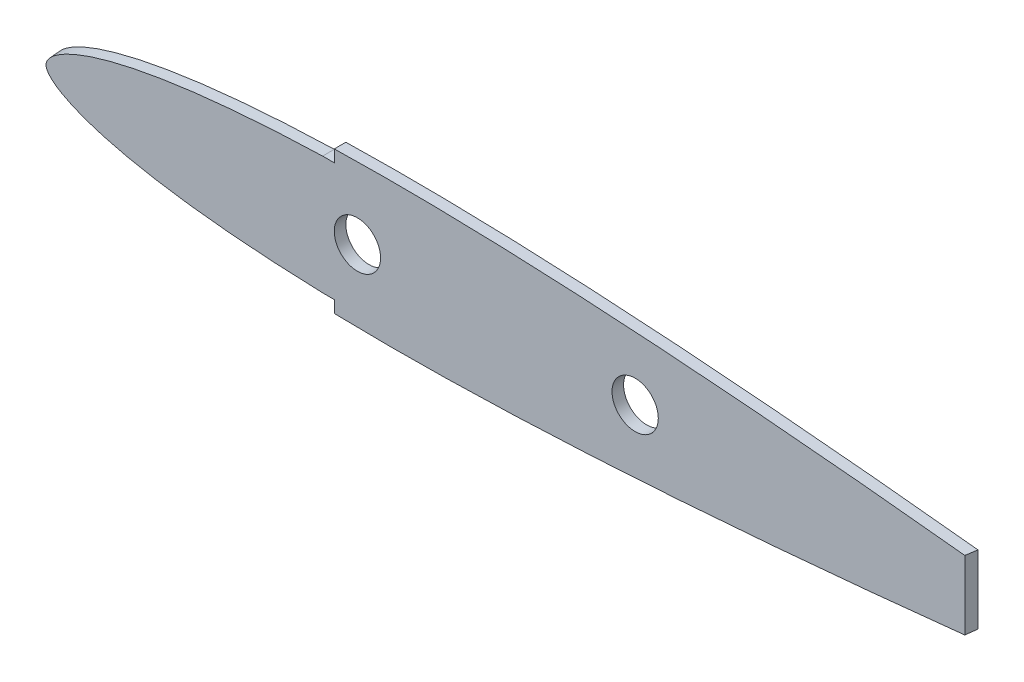
from build123d import *

# Parameters (mm, degrees)
BOSS_EXTRUDE1_DEPTH     = 3.175
SKETCH2_R               = 6.35
CUT_EXTRUDE1_DEPTH      = 4.1750001
CUT_EXTRUDE2_DEPTH      = 20.741500936
CUT_EXTRUDE2_DEPTH_BACK = 20.741500936


with BuildPart() as part:
    # Sketch1 → Boss-Extrude1 (new body)
    with BuildSketch(Plane.XY):
        with BuildLine():
            add(Edge.make_bspline(
                [(328.93, 0.4144518), (328.807900642, 0.516772717), (328.019000541, 0.420161926), (326.614170865, 0.815622818), (324.037900124, 1.060053788), (320.567272172, 1.584632638), (316.096583479, 2.170027594), (310.705215164, 2.891499965), (304.407193949, 3.70705594), (297.248126622, 4.61507178), (289.269853683, 5.599640546), (280.522284399, 6.647437516), (271.05918713, 7.745466949), (260.938835986, 8.878779448), (250.223661724, 10.033538187), (238.979802735, 11.195400912), (227.276553794, 12.349370833), (215.186101231, 13.479249677), (202.78290329, 14.570204468), (190.143565404, 15.603996393), (177.345750776, 16.563769435), (164.468478458, 17.43170464), (151.591090461, 18.189654233), (138.792862913, 18.818469572), (126.15283726, 19.301382712), (113.748578816, 19.622639213), (101.656743367, 19.766547691), (89.951630239, 19.721687508), (78.705404506, 19.479393557), (67.987291822, 19.033523951), (57.863264224, 18.382912366), (48.395544354, 17.529516447), (39.642067919, 16.480001255), (31.656190162, 15.24329661), (24.486303571, 13.832318834), (18.174431838, 12.263022231), (12.756441756, 10.550709399), (8.259860269, 8.711328155), (4.699027102, 6.757322776), (2.079421527, 4.684836659), (0.401585469, 2.443731656), (-0.187153107, 0), (0.401585469, -2.443731656), (2.079421527, -4.684836659), (4.699027102, -6.757322776), (8.259860269, -8.711328155), (12.756441756, -10.550709399), (18.174431838, -12.263022231), (24.486303571, -13.832318834), (31.656190162, -15.24329661), (39.642067919, -16.480001255), (48.395544354, -17.529516447), (57.863264224, -18.382912366), (67.987291822, -19.033523951), (78.705404506, -19.479393557), (89.951630239, -19.721687508), (101.656743367, -19.766547691), (113.748578816, -19.622639213), (126.15283726, -19.301382712), (138.792862913, -18.818469572), (151.591090461, -18.189654233), (164.468478458, -17.43170464), (177.345750776, -16.563769435), (190.143565404, -15.603996393), (202.78290329, -14.570204468), (215.186101231, -13.479249677), (227.276553794, -12.349370833), (238.979802735, -11.195400912), (250.223661724, -10.033538187), (260.938835986, -8.878779448), (271.05918713, -7.745466949), (280.522284399, -6.647437516), (289.269853683, -5.599640546), (297.248126622, -4.61507178), (304.407193949, -3.70705594), (310.705215164, -2.891499965), (316.096583479, -2.170027594), (320.567272172, -1.584632638), (324.037900124, -1.060053788), (326.614170865, -0.815622818), (328.019000541, -0.420161926), (329.127736254, -0.555940631), (329.127736254, 0.24874614), (328.93, 0.4144518)],
                knots=[0, 0, 0, 0, 0.000762215, 0.003044706, 0.006832246, 0.012101176, 0.018817536, 0.026939455, 0.036414848, 0.047184629, 0.059180413, 0.072327874, 0.086544061, 0.10174058, 0.117823336, 0.134691452, 0.152240154, 0.17036129, 0.188941008, 0.207865435, 0.227016078, 0.246275696, 0.265524943, 0.284644966, 0.303520118, 0.322034575, 0.340078353, 0.357542593, 0.374325482, 0.390329891, 0.40546389, 0.419643801, 0.432793371, 0.444843817, 0.455737921, 0.465428653, 0.47388632, 0.481101634, 0.487101684, 0.491975368, 0.495930678, 0.499382808, 0.502834938, 0.506790248, 0.511663932, 0.517663982, 0.524879296, 0.533336963, 0.543027695, 0.553921799, 0.565972245, 0.579121815, 0.593301726, 0.608435725, 0.624440134, 0.641223023, 0.658687263, 0.676731041, 0.695245498, 0.71412065, 0.733240673, 0.75248992, 0.771749538, 0.790900181, 0.809824608, 0.828404326, 0.846525462, 0.864074164, 0.88094228, 0.897025036, 0.912221555, 0.926437743, 0.939585203, 0.951580988, 0.962350768, 0.971826161, 0.979948081, 0.98666444, 0.991933371, 0.99572091, 0.998003402, 0.998765616, 1, 1, 1, 1], degree=3))
        make_face()
    extrude(amount=BOSS_EXTRUDE1_DEPTH)

    # Sketch2 → Cut-Extrude1 (cut, through all)
    with BuildSketch(Plane.XY.offset(3.175)):
        with Locations((88.9, 0)):
            Circle(SKETCH2_R)
        with Locations((165.1, 0)):
            Circle(SKETCH2_R)
    extrude(amount=-CUT_EXTRUDE1_DEPTH, mode=Mode.SUBTRACT)

    # Sketch3 → Cut-Extrude2 (cut, two sides)
    with BuildSketch(Plane(origin=(0, 0, 0), x_dir=(1, 0, 0), z_dir=(0, 1, 0))) as cut_extrude2_sk:
        Polygon((255.992242673, 0), (255.545593987, -3.175), (329.07830219, -3.175), (329.07830219, 0), align=None)
    extrude(amount=CUT_EXTRUDE2_DEPTH, mode=Mode.SUBTRACT)
    extrude(cut_extrude2_sk.sketch, amount=-CUT_EXTRUDE2_DEPTH_BACK, mode=Mode.SUBTRACT)

    # Sketch4 → Cut-Loft1 section 0
    with BuildSketch(Plane.XY.offset(3.175)):
        with BuildLine():
            Line((82.55, -19.515708197), (82.55, -16.251023077))
            Line((82.55, -16.251023077), (79.375, -16.251023077))
            add(Edge.make_bspline(
                [(79.375, 16.251023077), (72.770318552, 16.048049675), (66.176202719, 15.728304371), (56.30738853, 15.001567412), (53.021532705, 14.717888762), (46.459157571, 14.04734399), (43.182596705, 13.660937457), (38.276882967, 12.980450934), (36.643177419, 12.736779299), (33.379494145, 12.209172355), (31.748117674, 11.925180268), (28.498717967, 11.31067673), (26.880571377, 10.97988905), (23.660292552, 10.260780921), (22.058116365, 9.87261787), (18.875212279, 9.019251619), (17.293996052, 8.555526619), (14.162834442, 7.517257926), (12.611952901, 6.946125273), (10.325000489, 5.950076454), (9.567811499, 5.594025093), (8.461932827, 5.017489815), (8.097932617, 4.81777412), (7.381669561, 4.39922172), (7.029407018, 4.180395983), (6.339282138, 3.719594292), (6.001169966, 3.47795005), (5.346762375, 2.959692647), (5.02857237, 2.681117584), (4.439349211, 2.084395549), (4.164695388, 1.768387828), (3.820228536, 1.236176286), (3.718740433, 1.050561172), (3.59999989, 0.759299745), (3.565442077, 0.659141625), (3.509216677, 0.455376556), (3.487522742, 0.351764773), (3.459675736, 0.143592536), (3.453573255, 0.038940089), (3.461444597, -0.171798071), (3.474973766, -0.278422694), (3.536160139, -0.588423887), (3.603651886, -0.78636311), (3.780189655, -1.168677669), (3.889538593, -1.351988295), (4.129382817, -1.699026003), (4.261329389, -1.864987348), (4.67775825, -2.342961513), (4.979594961, -2.63427888), (5.614334641, -3.181856059), (5.947755344, -3.437548737), (6.980186178, -4.167859174), (7.695486627, -4.59881642), (9.156342741, -5.391257516), (9.902423269, -5.75319572), (11.414841066, -6.432708068), (12.181579116, -6.749404985), (13.73156777, -7.346635451), (14.514836956, -7.627179806), (16.093189665, -8.161972373), (16.88860874, -8.415184993), (18.482918694, -8.896317804), (19.282763312, -9.124717403), (21.688920309, -9.779957105), (23.302005405, -10.176164111), (26.541461257, -10.908476052), (28.167798474, -11.244732377), (33.062961618, -12.180447863), (36.350545365, -12.709560737), (42.938422768, -13.630876096), (46.23811967, -14.02274496), (52.84624923, -14.702163706), (56.154743063, -14.989298509), (66.090451195, -15.724271447), (72.727906329, -16.046777883), (79.375, -16.251023077)],
                knots=[0, 0, 0, 0, 0.125, 0.125, 0.1875, 0.1875, 0.25, 0.25, 0.28125, 0.28125, 0.3125, 0.3125, 0.34375, 0.34375, 0.375, 0.375, 0.40625, 0.40625, 0.4375, 0.4375, 0.453125, 0.453125, 0.4609375, 0.4609375, 0.46875, 0.46875, 0.4765625, 0.4765625, 0.484375, 0.484375, 0.4921875, 0.4921875, 0.49609375, 0.49609375, 0.498046875, 0.498046875, 0.5, 0.5, 0.501953125, 0.501953125, 0.50390625, 0.50390625, 0.5078125, 0.5078125, 0.51171875, 0.51171875, 0.515625, 0.515625, 0.5234375, 0.5234375, 0.53125, 0.53125, 0.546875, 0.546875, 0.5625, 0.5625, 0.578125, 0.578125, 0.59375, 0.59375, 0.609375, 0.609375, 0.625, 0.625, 0.65625, 0.65625, 0.6875, 0.6875, 0.75, 0.75, 0.8125, 0.8125, 0.875, 0.875, 1, 1, 1, 1], degree=3))
            Line((79.375, 16.251023077), (82.55, 16.251023077))
            Line((82.55, 16.251023077), (82.55, 19.515708197))
            Line((82.55, 19.515708197), (82.55, 26.856724286))
            Line((82.55, 26.856724286), (0.541465363, 30.021162049))
            Line((0.541465363, 30.021162049), (-2.146488993, -32.850745924))
            Line((-2.146488993, -32.850745924), (82.55, -25.525605715))
            Line((82.55, -25.525605715), (82.55, -19.515708197))
        make_face()
    # Sketch5 → Cut-Loft1 section 1
    with BuildSketch(Plane(origin=(0, 0, 0), x_dir=(-1, 0, 0), z_dir=(0, 0, -1))):
        with BuildLine():
            Line((-82.55, 16.286875084), (-82.55, 19.550482394))
            Line((-82.55, 19.550482394), (-82.55, 31.358919225))
            Line((-82.55, 31.358919225), (6.781155494, 29.861379368))
            Line((6.781155494, 29.861379368), (6.781155494, -36.639095207))
            Line((6.781155494, -36.639095207), (-82.55, -25.525605715))
            Line((-82.55, -25.525605715), (-82.55, -19.550482394))
            Line((-82.55, -19.550482394), (-82.55, -16.286875084))
            Line((-82.55, -16.286875084), (-79.375, -16.286825084))
            add(Edge.make_bspline(
                [(-79.375, -16.286825084), (-72.70273318, -16.083625481), (-66.040162391, -15.761734789), (-56.066904089, -15.02675589), (-52.74593973, -14.739468648), (-46.112636154, -14.059312037), (-42.800262288, -13.666866819), (-36.186801437, -12.743811384), (-32.886327655, -12.2135267), (-27.972128974, -11.275498707), (-26.339484745, -10.938349054), (-23.087489601, -10.204046758), (-21.46817298, -9.806739324), (-19.052762163, -9.149552861), (-18.249847199, -8.920461216), (-16.649429662, -8.437847637), (-15.850951917, -8.18383552), (-13.474510425, -7.379098548), (-11.914239449, -6.789912299), (-9.637231735, -5.767068515), (-8.888396164, -5.403819393), (-7.422171814, -4.608342986), (-6.704241471, -4.175660987), (-5.668127182, -3.442181611), (-5.333636046, -3.185395684), (-4.696951467, -2.635333166), (-4.394240594, -2.342641179), (-3.976788262, -1.862235899), (-3.844582818, -1.695403026), (-3.604511152, -1.346529706), (-3.495161032, -1.162204789), (-3.319211947, -0.777827241), (-3.252263911, -0.578820545), (-3.192281327, -0.267197855), (-3.179223041, -0.160018081), (-3.172509862, 0.051695952), (-3.179309615, 0.15678123), (-3.223308922, 0.470243795), (-3.283913969, 0.67718865), (-3.444877784, 1.066367796), (-3.547583565, 1.252275918), (-3.89542395, 1.785311832), (-4.171725698, 2.101726419), (-4.764220619, 2.699573748), (-5.08404298, 2.978749304), (-5.741470891, 3.497921226), (-6.081013127, 3.739966717), (-7.120428348, 4.432428384), (-7.84199373, 4.847705574), (-9.322334636, 5.617984146), (-10.082577048, 5.974865708), (-12.378451328, 6.97306267), (-13.935068025, 7.545295509), (-17.077417964, 8.585489689), (-18.664115765, 9.049996772), (-21.858212178, 9.904877668), (-23.466047551, 10.293687362), (-26.697720209, 11.014001073), (-28.321602434, 11.345344154), (-31.582558999, 11.960787009), (-33.219741649, 12.245183343), (-36.494895711, 12.773474887), (-38.134297303, 13.017428152), (-43.057081916, 13.69860264), (-46.345031773, 14.085282453), (-52.93019877, 14.756080578), (-56.227457948, 15.039733656), (-66.130500011, 15.766027755), (-72.74745852, 16.084987562), (-79.375, 16.286825084)],
                knots=[0, 0, 0, 0, 0.125, 0.125, 0.1875, 0.1875, 0.25, 0.25, 0.3125, 0.3125, 0.34375, 0.34375, 0.375, 0.375, 0.390625, 0.390625, 0.40625, 0.40625, 0.4375, 0.4375, 0.453125, 0.453125, 0.46875, 0.46875, 0.4765625, 0.4765625, 0.484375, 0.484375, 0.48828125, 0.48828125, 0.4921875, 0.4921875, 0.49609375, 0.49609375, 0.498046875, 0.498046875, 0.5, 0.5, 0.50390625, 0.50390625, 0.5078125, 0.5078125, 0.515625, 0.515625, 0.5234375, 0.5234375, 0.53125, 0.53125, 0.546875, 0.546875, 0.5625, 0.5625, 0.59375, 0.59375, 0.625, 0.625, 0.65625, 0.65625, 0.6875, 0.6875, 0.71875, 0.71875, 0.75, 0.75, 0.8125, 0.8125, 0.875, 0.875, 1, 1, 1, 1], degree=3))
            Line((-79.375, 16.286825084), (-82.55, 16.286875084))
        make_face()
    loft(mode=Mode.SUBTRACT)


solid = part.part
